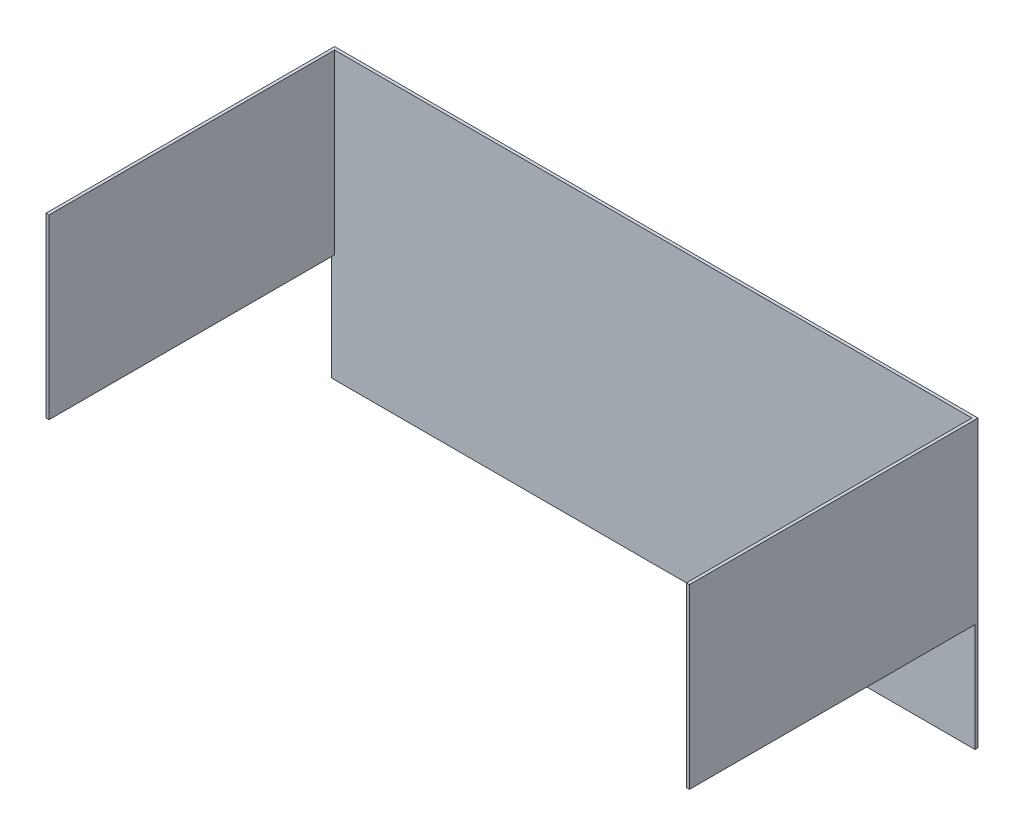
from build123d import *

# Parameters (mm, degrees)
EXTRUDE_THIN1_DEPTH     = 301.625
SKETCH2_W               = 301.625
SKETCH2_H               = 114.3
CUT_EXTRUDE1_DEPTH      = 677.275
CUT_EXTRUDE1_DEPTH_BACK = 4.175


with BuildPart() as part:
    # Sketch1 → Extrude-Thin1 (new body)
    with BuildSketch(Plane(origin=(0, 0, 0), x_dir=(1, 0, 0), z_dir=(0, 1, 0))):
        Polygon((-339.725, -152.4), (-339.725, 152.4), (339.725, 152.4), (339.725, -152.4), (336.55, -152.4), (336.55, 149.225), (-336.55, 149.225), (-336.55, -152.4), align=None)
    extrude(amount=EXTRUDE_THIN1_DEPTH)

    # Sketch2 → Cut-Extrude1 (cut, two sides)
    with BuildSketch(Plane(origin=(-336.55, 0, 0), x_dir=(0, 0, -1), z_dir=(1, 0, 0))) as cut_extrude1_sk:
        with Locations((-1.5875, 57.15)):
            Rectangle(SKETCH2_W, SKETCH2_H)
    extrude(amount=CUT_EXTRUDE1_DEPTH, mode=Mode.SUBTRACT)
    extrude(cut_extrude1_sk.sketch, amount=-CUT_EXTRUDE1_DEPTH_BACK, mode=Mode.SUBTRACT)


solid = part.part
